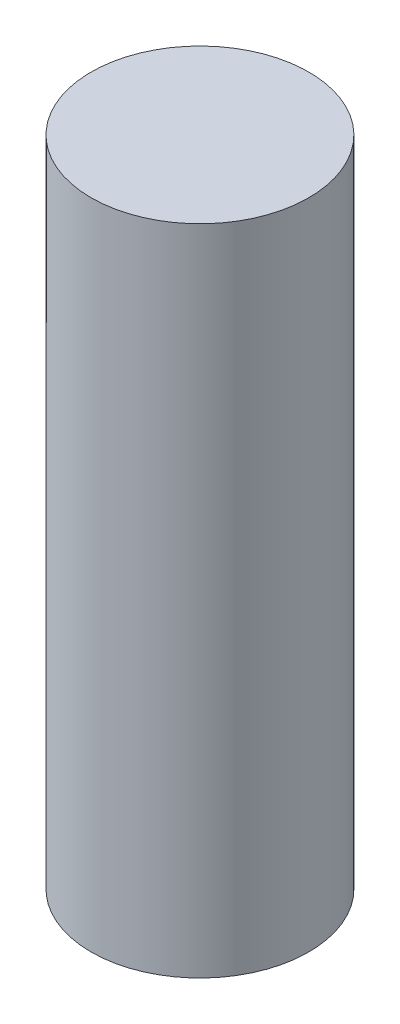
from build123d import *

# Parameters (mm, degrees)
SKETCH1_R           = 5
BOSS_EXTRUDE1_DEPTH = 30


with BuildPart() as part:
    # Sketch1 → Boss-Extrude1 (new body)
    with BuildSketch(Plane(origin=(0, 0, 0), x_dir=(1, 0, 0), z_dir=(0, 1, 0))):
        Circle(SKETCH1_R)
    extrude(amount=BOSS_EXTRUDE1_DEPTH)


solid = part.part
